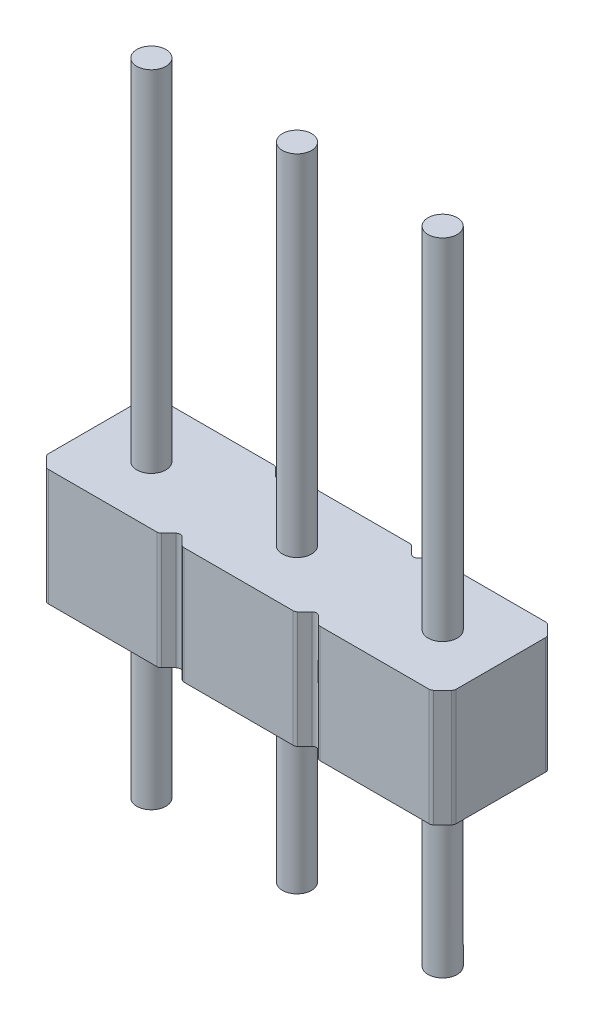
from build123d import *

# Parameters (mm, degrees)
IZIM1_R                          = 0.25
Y_KSEKLIK_EKSTR_ZYON1_DEPTH      = 2
IZIM3_R                          = 0.25
Y_KSEKLIK_EKSTR_ZYON3_DEPTH      = 6
Y_KSEKLIK_EKSTR_ZYON3_DEPTH_BACK = 5


with BuildPart() as part:
    # Çizim1 → Yükseklik-Ekstrüzyon1 (new body)
    with BuildSketch(Plane(origin=(0, 0, 0), x_dir=(1, 0, 0), z_dir=(0, 1, 0))):
        with BuildLine():
            Line((-3.477652227, 0.822347773), (-3.322347773, 0.977652227))
            ThreePointArc((-3.322347773, 0.977652227), (-3.297594249, 0.994192003), (-3.268395476, 1))
            Line((-3.268395476, 1), (-1.401604524, 1))
            ThreePointArc((-1.401604524, 1), (-1.372405751, 0.994192003), (-1.347652227, 0.977652227))
            Line((-1.347652227, 0.977652227), (-1.223952297, 0.853952297))
            ThreePointArc((-1.223952297, 0.853952297), (-1.17, 0.831604524), (-1.116047703, 0.853952297))
            Line((-1.116047703, 0.853952297), (-0.992347773, 0.977652227))
            ThreePointArc((-0.992347773, 0.977652227), (-0.967594249, 0.994192003), (-0.938395476, 1))
            Line((-0.938395476, 1), (0.935062143, 1))
            ThreePointArc((0.935062143, 1), (0.964260916, 0.994192003), (0.98901444, 0.977652227))
            Line((0.98901444, 0.977652227), (1.11271437, 0.853952297))
            ThreePointArc((1.11271437, 0.853952297), (1.166666667, 0.831604524), (1.220618963, 0.853952297))
            Line((1.220618963, 0.853952297), (1.344318894, 0.977652227))
            ThreePointArc((1.344318894, 0.977652227), (1.369072418, 0.994192003), (1.39827119, 1))
            Line((1.39827119, 1), (3.268395476, 1))
            ThreePointArc((3.268395476, 1), (3.297594249, 0.994192003), (3.322347773, 0.977652227))
            Line((3.322347773, 0.977652227), (3.477652227, 0.822347773))
            ThreePointArc((3.477652227, 0.822347773), (3.494192003, 0.797594249), (3.5, 0.768395476))
            Line((3.5, 0.768395476), (3.5, -0.768395476))
            ThreePointArc((3.5, -0.768395476), (3.494192003, -0.797594249), (3.477652227, -0.822347773))
            Line((3.477652227, -0.822347773), (3.322347773, -0.977652227))
            ThreePointArc((3.322347773, -0.977652227), (3.297594249, -0.994192003), (3.268395476, -1))
            Line((3.268395476, -1), (1.39827119, -1))
            ThreePointArc((1.39827119, -1), (1.369072418, -0.994192003), (1.344318894, -0.977652227))
            Line((1.344318894, -0.977652227), (1.220618963, -0.853952297))
            ThreePointArc((1.220618963, -0.853952297), (1.166666667, -0.831604524), (1.11271437, -0.853952297))
            Line((1.11271437, -0.853952297), (0.98901444, -0.977652227))
            ThreePointArc((0.98901444, -0.977652227), (0.964260916, -0.994192003), (0.935062143, -1))
            Line((0.935062143, -1), (-0.938395476, -1))
            ThreePointArc((-0.938395476, -1), (-0.967594249, -0.994192003), (-0.992347773, -0.977652227))
            Line((-0.992347773, -0.977652227), (-1.116047703, -0.853952297))
            ThreePointArc((-1.116047703, -0.853952297), (-1.17, -0.831604524), (-1.223952297, -0.853952297))
            Line((-1.223952297, -0.853952297), (-1.347652227, -0.977652227))
            ThreePointArc((-1.347652227, -0.977652227), (-1.372405751, -0.994192003), (-1.401604524, -1))
            Line((-1.401604524, -1), (-3.268395476, -1))
            ThreePointArc((-3.268395476, -1), (-3.297594249, -0.994192003), (-3.322347773, -0.977652227))
            Line((-3.322347773, -0.977652227), (-3.477652227, -0.822347773))
            ThreePointArc((-3.477652227, -0.822347773), (-3.494192003, -0.797594249), (-3.5, -0.768395476))
            Line((-3.5, -0.768395476), (-3.5, 0.768395476))
            ThreePointArc((-3.5, 0.768395476), (-3.494192003, 0.797594249), (-3.477652227, 0.822347773))
        make_face()
        Circle(IZIM1_R, mode=Mode.SUBTRACT)
        with Locations((-2.5, 0)):
            Circle(IZIM1_R, mode=Mode.SUBTRACT)
        with Locations((2.5, 0)):
            Circle(IZIM1_R, mode=Mode.SUBTRACT)
    extrude(amount=Y_KSEKLIK_EKSTR_ZYON1_DEPTH)

    # Çizim3 → Yükseklik-Ekstrüzyon3 (add, two sides)
    with BuildSketch(Plane(origin=(0, 2, 0), x_dir=(1, 0, 0), z_dir=(0, 1, 0))) as y_kseklik_ekstr_zyon3_sk:
        with Locations((-2.5, 0)):
            Circle(IZIM3_R)
        Circle(IZIM3_R)
        with Locations((2.5, 0)):
            Circle(IZIM3_R)
    extrude(amount=Y_KSEKLIK_EKSTR_ZYON3_DEPTH)
    extrude(y_kseklik_ekstr_zyon3_sk.sketch, amount=-Y_KSEKLIK_EKSTR_ZYON3_DEPTH_BACK)


solid = part.part
